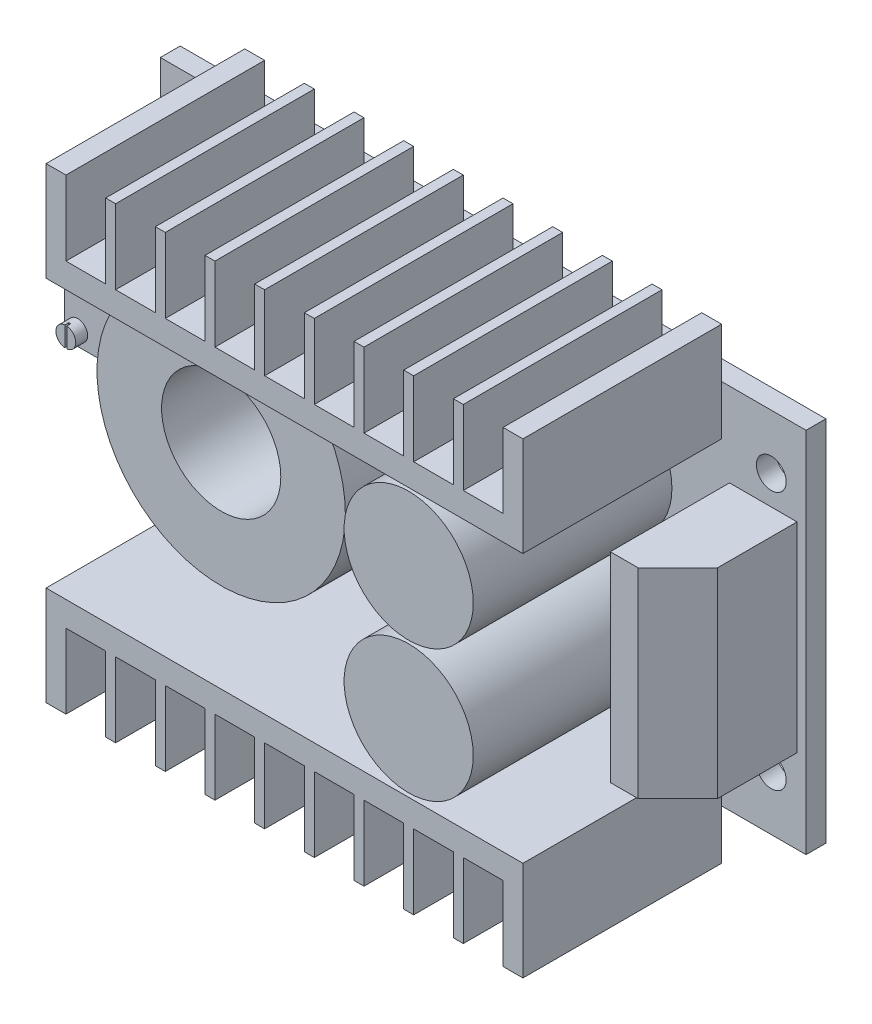
from build123d import *

# Parameters (mm, degrees)
SKETCH_1_W          = 65
SKETCH_1_H          = 37
EXTRUDE_1_DEPTH     = 2
EXTRUDE_2_DEPTH     = 20
SKETCH_3_R          = 6.5
EXTRUDE_3_DEPTH     = 20
SKETCH_4_R          = 12.5
SKETCH_4_R_2        = 6
EXTRUDE_4_DEPTH     = 12
SKETCH_5_W          = 5
SKETCH_5_H          = 10
EXTRUDE_5_DEPTH     = 10
SKETCH_6_R          = 1
EXTRUDE_6_DEPTH     = 1.2
SKETCH_7_W          = 6.798722996
SKETCH_7_H          = 20.12306807
EXTRUDE_7_DEPTH     = 12
CHAMFER_1_SIZE      = 4
SKETCH_8_R          = 1.5
CUT_EXTRUDE_1_DEPTH = 3
SKETCH1_W           = 0.2
SKETCH1_H           = 2.227006651
CUT_EXTRUDE1_DEPTH  = 0.4


with BuildPart() as part:
    # Эскиз1 → Бобышка-Вытянуть1 (new body)
    with BuildSketch(Plane.XY):
        Rectangle(SKETCH_1_W, SKETCH_1_H)
    extrude(amount=EXTRUDE_1_DEPTH)

    # Эскиз2 → Бобышка-Вытянуть2 (add)
    with BuildSketch(Plane.XY.offset(2)):
        Polygon((-24, 23.5), (-24, 13.5), (24, 13.5), (24, 23.5), (22, 23.5), (22, 16), (18, 16), (18, 23.5), (17, 23.5), (17, 16), (13, 16), (13, 23.5), (12, 23.5), (12, 16), (8, 16), (8, 23.5), (7, 23.5), (7, 16), (3, 16), (3, 23.5), (2, 23.5), (2, 16), (-2, 16), (-2, 23.5), (-3, 23.5), (-3, 16), (-7, 16), (-7, 23.5), (-8, 23.5), (-8, 16), (-12, 16), (-12, 23.5), (-13, 23.5), (-13, 16), (-17, 16), (-17, 23.5), (-18, 23.5), (-18, 16), (-22, 16), (-22, 23.5), align=None)
        Polygon((22, -23.5), (24, -23.5), (24, -13.5), (-24, -13.5), (-24, -23.5), (-22, -23.5), (-22, -16), (-18, -16), (-18, -23.5), (-17, -23.5), (-17, -16), (-13, -16), (-13, -23.5), (-12, -23.5), (-12, -16), (-8, -16), (-8, -23.5), (-7, -23.5), (-7, -16), (-3, -16), (-3, -23.5), (-2, -23.5), (-2, -16), (2, -16), (2, -23.5), (3, -23.5), (3, -16), (7, -16), (7, -23.5), (8, -23.5), (8, -16), (12, -16), (12, -23.5), (13, -23.5), (13, -16), (17, -16), (17, -23.5), (18, -23.5), (18, -16), (22, -16), align=None)
    extrude(amount=EXTRUDE_2_DEPTH)

    # Эскиз3 → Бобышка-Вытянуть3 (add)
    with BuildSketch(Plane.XY.offset(2)):
        with Locations((12.5, 6.691570058)):
            Circle(SKETCH_3_R)
        with Locations((12.5, -6.612413993)):
            Circle(SKETCH_3_R)
    extrude(amount=EXTRUDE_3_DEPTH)

    # Эскиз4 → Бобышка-Вытянуть4 (add)
    with BuildSketch(Plane.XY.offset(2)):
        with Locations((-14.373526478, 0)):
            Circle(SKETCH_4_R)
        with Locations((-14.373526478, 0)):
            Circle(SKETCH_4_R_2, mode=Mode.SUBTRACT)
    extrude(amount=EXTRUDE_4_DEPTH)

    # Эскиз5 → Бобышка-Вытянуть5 (add)
    with BuildSketch(Plane.XY.offset(2)):
        with Locations((-29.649429854, 4.142703247)):
            Rectangle(SKETCH_5_W, SKETCH_5_H)
    extrude(amount=EXTRUDE_5_DEPTH)

    # Эскиз6 → Бобышка-Вытянуть6 (add)
    with BuildSketch(Plane.XY.offset(12)):
        with Locations((-30.813495229, 0.582032688)):
            Circle(SKETCH_6_R)
    extrude(amount=EXTRUDE_6_DEPTH)

    # Эскиз7 → Бобышка-Вытянуть7 (add)
    with BuildSketch(Plane.XY.offset(2)):
        with Locations((28.195350692, 0)):
            Rectangle(SKETCH_7_W, SKETCH_7_H)
    extrude(amount=EXTRUDE_7_DEPTH)

    # Фаска1
    chamfer_1_edges = [part.edges().sort_by_distance(p)[0] for p in [
        (31.59471219, 0, 14),
    ]]
    chamfer(chamfer_1_edges, length=CHAMFER_1_SIZE)

    # Эскиз8 → Вырез-Вытянуть1 (cut, through all)
    with BuildSketch(Plane.XY.offset(2)):
        with Locations((-29, 13)):
            Circle(SKETCH_8_R)
        with Locations((29, 13)):
            Circle(SKETCH_8_R)
        with Locations((29, -13)):
            Circle(SKETCH_8_R)
        with Locations((-29, -13)):
            Circle(SKETCH_8_R)
    extrude(amount=-CUT_EXTRUDE_1_DEPTH, mode=Mode.SUBTRACT)

    # Sketch1 → Cut-Extrude1 (cut)
    with BuildSketch(Plane.XY.offset(13.2)):
        with Locations((-30.813495229, 0.505684331)):
            Rectangle(SKETCH1_W, SKETCH1_H)
    extrude(amount=-CUT_EXTRUDE1_DEPTH, mode=Mode.SUBTRACT)


solid = part.part
